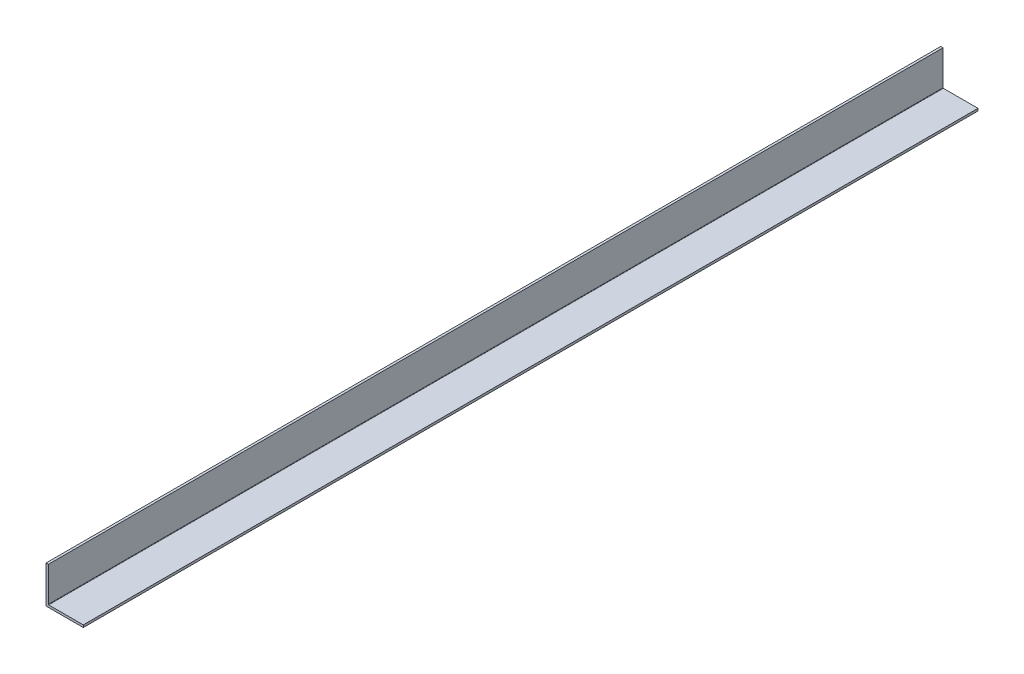
from build123d import *

# Parameters (mm, degrees)
BOSS_EXTRUDE1_DEPTH = 304.8
FILLET1_R           = 0.254


with BuildPart() as part:
    # Sketch3 → Boss-Extrude1 (new, symmetric)
    with BuildSketch(Plane.XY):
        Polygon((1.5875, 25.4), (0, 25.4), (0, 0), (25.4, 0), (25.4, 1.5875), (1.5875, 1.5875), align=None)
    extrude(amount=BOSS_EXTRUDE1_DEPTH, both=True)

    # Fillet1
    fillet1_edges = [part.edges().sort_by_distance(p)[0] for p in [
        (1.5875, 1.5875, 0),
    ]]
    fillet(fillet1_edges, radius=FILLET1_R)


solid = part.part
